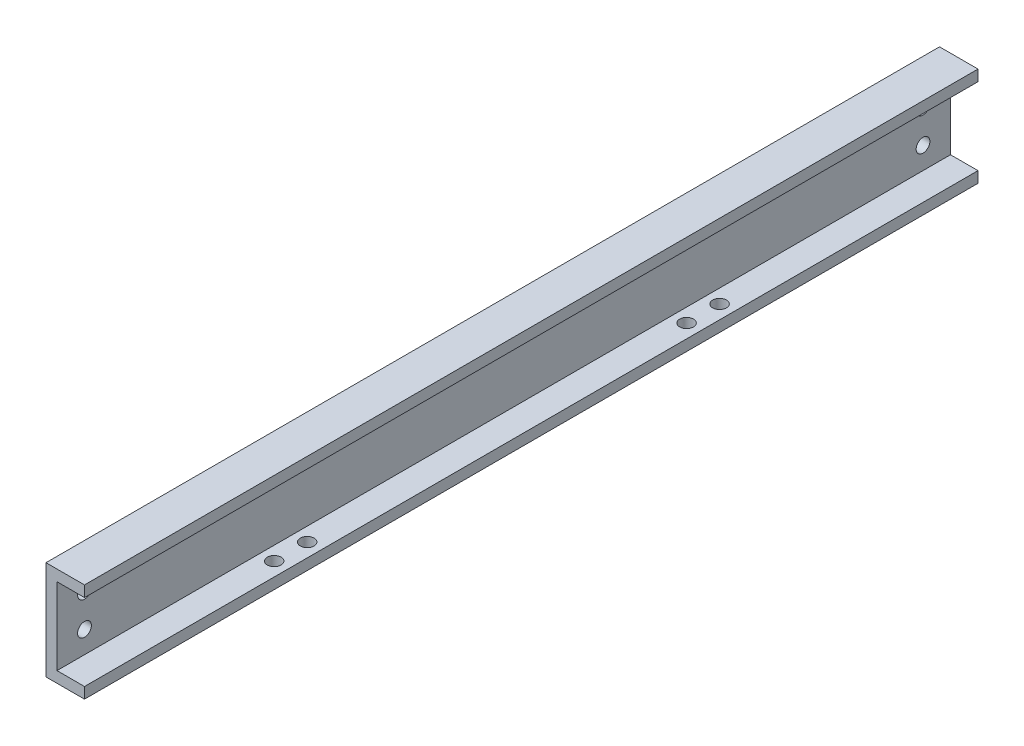
from build123d import *

# Parameters (mm, degrees)
BOSS_EXTRUDE1_DEPTH = 162.5
SKETCH2_R           = 1.25
CUT_EXTRUDE1_DEPTH  = 8
CUT_EXTRUDE2_DEPTH  = 1
SKETCH4_R           = 1.25
CUT_EXTRUDE3_DEPTH  = 3


with BuildPart() as part:
    # Sketch1 → Boss-Extrude1 (new body)
    with BuildSketch(Plane.XY):
        Polygon((0, 9), (0, -9), (7, -9), (7, -7), (2, -7), (2, 7), (7, 7), (7, 9), align=None)
    extrude(amount=-BOSS_EXTRUDE1_DEPTH)

    # Sketch2 → Cut-Extrude1 (cut, through all)
    with BuildSketch(Plane.ZY):
        with Locations((-5, 3)):
            Circle(SKETCH2_R)
        with Locations((-5, -3)):
            Circle(SKETCH2_R)
        with Locations((-157.5, -3)):
            Circle(SKETCH2_R)
        with Locations((-157.5, 3)):
            Circle(SKETCH2_R)
    extrude(amount=-CUT_EXTRUDE1_DEPTH, mode=Mode.SUBTRACT)

    # Sketch3 → Cut-Extrude2 (cut)
    with BuildSketch(Plane.ZY):
        Polygon((-8.84619024, 4.575146227), (-7.141062035, 4.575146227), (-7.141062035, 4.216171868), (-8.532087676, 4.216171868), (-8.532087676, 3.139248791), (-7.141062035, 3.139248791), (-7.141062035, 2.780274432), (-8.532087676, 2.780274432), (-8.532087676, 1.075146227), (-8.84619024, 1.075146227), align=None)
    extrude(amount=-CUT_EXTRUDE2_DEPTH, mode=Mode.SUBTRACT)

    # Sketch4 → Cut-Extrude3 (cut)
    with BuildSketch(Plane.XZ.offset(9)):
        with Locations((4.5, -37)):
            Circle(SKETCH4_R)
        with Locations((4.5, -43)):
            Circle(SKETCH4_R)
        with Locations((4.5, -112)):
            Circle(SKETCH4_R)
        with Locations((4.5, -118)):
            Circle(SKETCH4_R)
    extrude(amount=-CUT_EXTRUDE3_DEPTH, mode=Mode.SUBTRACT)


solid = part.part
